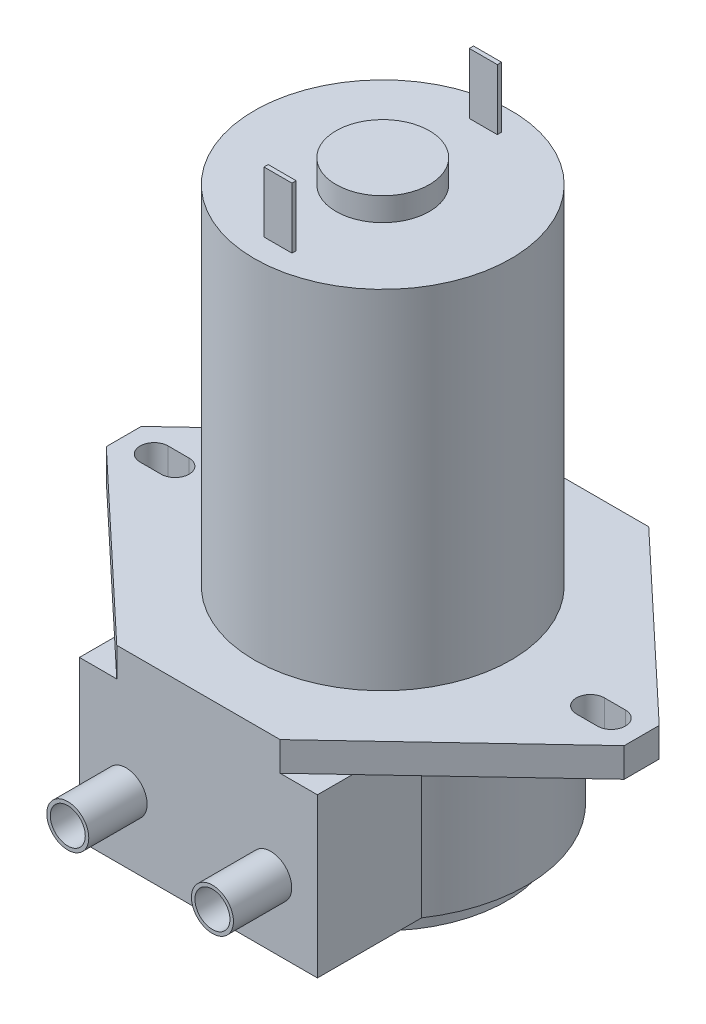
from build123d import *

# Parameters (mm, degrees)
BOSS_EXTRUDE1_DEPTH   = 3.175
SKETCH2_R             = 13.97
BOSS_EXTRUDE2_DEPTH   = 37.846
SKETCH3_R             = 5.08
BOSS_EXTRUDE3_DEPTH   = 2.54
SKETCH5_W             = 3.048
SKETCH5_H             = 0.4572
BOSS_EXTRUDE4_DEPTH   = 6.604
BOSS_EXTRUDE4_2_DEPTH = 6.604
BOSS_EXTRUDE5_DEPTH   = 17.272
SKETCH7_R             = 13.462
BOSS_EXTRUDE6_DEPTH   = 2.54
SKETCH8_R             = 2.286
BOSS_EXTRUDE7_DEPTH   = 6.35
SKETCH9_R             = 1.905
CUT_EXTRUDE1_DEPTH    = 6.35
CUT_EXTRUDE2_DEPTH    = 3.175


with BuildPart() as part:
    # Sketch1 → Boss-Extrude1 (new body)
    with BuildSketch(Plane(origin=(0, 0, 0), x_dir=(1, 0, 0), z_dir=(0, 1, 0))):
        Polygon((-17.268720614, 17.284574257), (0.511279386, 17.284574257), (19.815279386, -0.876425743), (19.815279386, -4.686425743), (0.511279386, -22.847425743), (-17.268720614, -22.847425743), (-36.572720614, -4.686425743), (-36.572720614, -0.876425743), align=None)
    extrude(amount=BOSS_EXTRUDE1_DEPTH)

    # Sketch2 → Boss-Extrude2 (add)
    with BuildSketch(Plane(origin=(0, 3.175, 0), x_dir=(1, 0, 0), z_dir=(0, 1, 0))):
        with Locations((-8.378720614, -2.781425743)):
            Circle(SKETCH2_R)
    extrude(amount=BOSS_EXTRUDE2_DEPTH)

    # Sketch3 → Boss-Extrude3 (add)
    with BuildSketch(Plane(origin=(0, 41.021, 0), x_dir=(1, 0, 0), z_dir=(0, 1, 0))):
        with Locations((-8.378720614, -2.781425743)):
            Circle(SKETCH3_R)
    extrude(amount=BOSS_EXTRUDE3_DEPTH)

    # Sketch6 → Boss-Extrude5 (add)
    with BuildSketch(Plane.XZ):
        with BuildLine():
            Line((-21.100004151, 22.847425743), (4.575279386, 22.847425743))
            Line((4.575279386, 22.847425743), (4.575279386, 11.511232441))
            ThreePointArc((4.575279386, 11.511232441), (-8.378720614, -12.839574257), (-21.332720614, 11.511232441))
            Line((-21.332720614, 11.511232441), (-21.332720614, 22.847425743))
            Line((-21.332720614, 22.847425743), (-21.100004151, 22.847425743))
        make_face()
    extrude(amount=BOSS_EXTRUDE5_DEPTH)

    # Sketch7 → Boss-Extrude6 (add)
    with BuildSketch(Plane.XZ.offset(17.272)):
        with Locations((-8.378720614, 2.781425743)):
            Circle(SKETCH7_R)
    extrude(amount=BOSS_EXTRUDE6_DEPTH)

    # Sketch8 → Boss-Extrude7 (add)
    with BuildSketch(Plane.XY.offset(22.847425743)):
        with Locations((-0.504720614, -10.16)):
            Circle(SKETCH8_R)
        with Locations((-16.252720614, -10.16)):
            Circle(SKETCH8_R)
    extrude(amount=BOSS_EXTRUDE7_DEPTH)

    # Sketch9 → Cut-Extrude1 (cut)
    with BuildSketch(Plane.XY.offset(29.197425743)):
        with Locations((-0.504720614, -10.16)):
            Circle(SKETCH9_R)
        with Locations((-16.252720614, -10.16)):
            Circle(SKETCH9_R)
    extrude(amount=-CUT_EXTRUDE1_DEPTH, mode=Mode.SUBTRACT)

    # Sketch10 → Cut-Extrude2 (cut)
    with BuildSketch(Plane.XZ):
        with BuildLine():
            Line((16.513279386, 1.257425743), (14.227279386, 1.257425743))
            ThreePointArc((14.227279386, 1.257425743), (12.703279386, 2.781425743), (14.227279386, 4.305425743))
            Line((14.227279386, 4.305425743), (16.513279386, 4.305425743))
            ThreePointArc((16.513279386, 4.305425743), (18.037279386, 2.781425743), (16.513279386, 1.257425743))
        make_face()
        with BuildLine():
            Line((-33.270720614, 1.257425743), (-30.984720614, 1.257425743))
            ThreePointArc((-30.984720614, 1.257425743), (-29.460720614, 2.781425743), (-30.984720614, 4.305425743))
            Line((-30.984720614, 4.305425743), (-33.270720614, 4.305425743))
            ThreePointArc((-33.270720614, 4.305425743), (-34.794720614, 2.781425743), (-33.270720614, 1.257425743))
        make_face()
    extrude(amount=-CUT_EXTRUDE2_DEPTH, mode=Mode.SUBTRACT)


with BuildPart() as body_2:
    # Sketch5 → Boss-Extrude4 (new body)
    with BuildSketch(Plane(origin=(0, 41.021, 0), x_dir=(1, 0, 0), z_dir=(0, 1, 0))):
        with Locations((-8.378720614, 8.394574257)):
            Rectangle(SKETCH5_W, SKETCH5_H)
    extrude(amount=BOSS_EXTRUDE4_DEPTH)


with BuildPart() as body_3:
    # Sketch5 → Boss-Extrude4 2 (new body)
    with BuildSketch(Plane(origin=(0, 41.021, 0), x_dir=(1, 0, 0), z_dir=(0, 1, 0))):
        with Locations((-8.378720614, -13.957425743)):
            Rectangle(SKETCH5_W, SKETCH5_H)
    extrude(amount=BOSS_EXTRUDE4_2_DEPTH)


solid = Compound([part.part, body_2.part, body_3.part])
